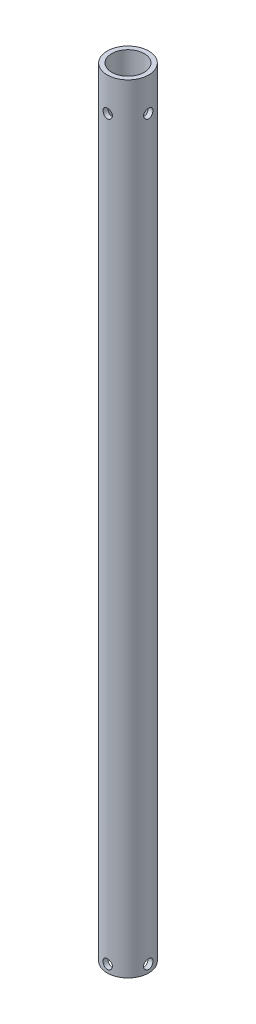
from build123d import *

# Parameters (mm, degrees)
SKETCH1_R           = 13.35
SKETCH1_R_2         = 10.45
BOSS_EXTRUDE1_DEPTH = 250
SKETCH2_R           = 3
CUT_EXTRUDE1_DEPTH  = 14.35
CIRPATTERN1_COUNT   = 2
CIRPATTERN1_ANGLE   = 90


with BuildPart() as part:
    # Sketch1 → Boss-Extrude1 (new body, symmetric)
    with BuildSketch(Plane(origin=(0, 0, 0), x_dir=(1, 0, 0), z_dir=(0, 1, 0))):
        Circle(SKETCH1_R)
        Circle(SKETCH1_R_2, mode=Mode.SUBTRACT)
    extrude(amount=BOSS_EXTRUDE1_DEPTH, both=True)

    # Sketch2 → Cut-Extrude1 (cut, through all)
    with BuildSketch(Plane.XY):
        with Locations((0, 228.58)):
            Circle(SKETCH2_R)
        with Locations((0, -245)):
            Circle(SKETCH2_R)
    cut_extrude1 = extrude(amount=CUT_EXTRUDE1_DEPTH, mode=Mode.SUBTRACT)

    # CirPattern1: Cut-Extrude1 ×2 about axis
    cirpattern1_axis = Axis((0, 250, 0), (0, 1, 0))
    for i in range(1, CIRPATTERN1_COUNT):
        add(cut_extrude1.rotate(cirpattern1_axis, i * CIRPATTERN1_ANGLE / (CIRPATTERN1_COUNT - 1)), mode=Mode.SUBTRACT)


solid = part.part
